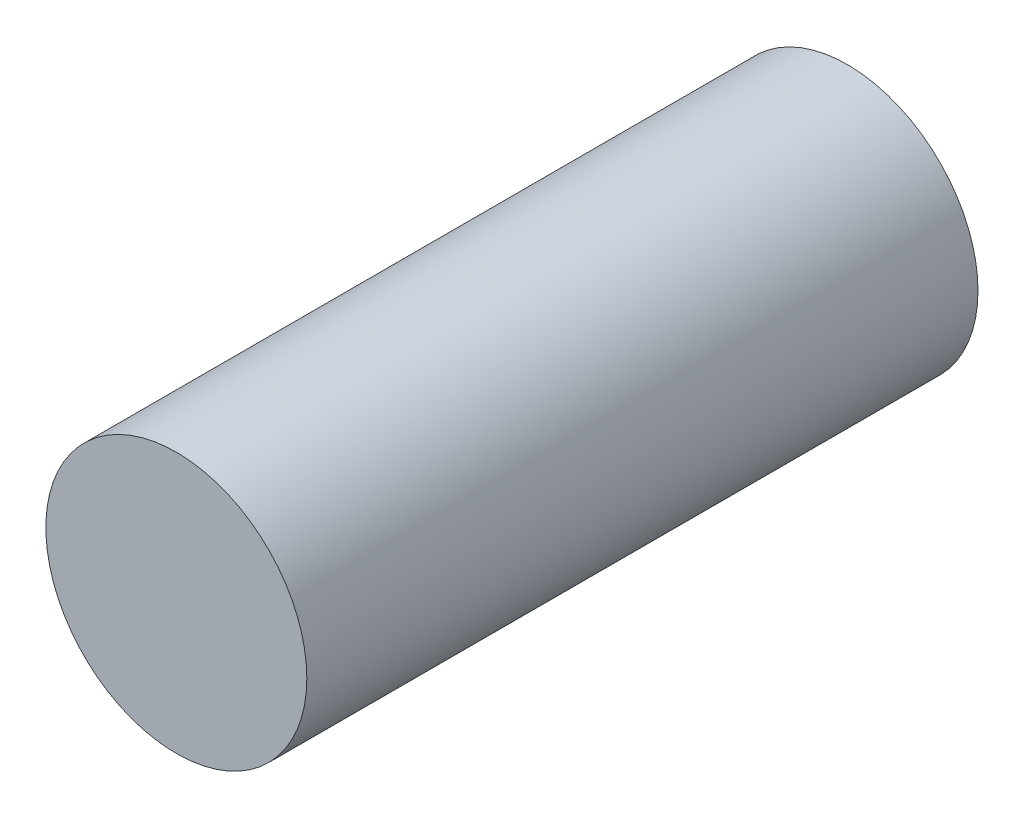
from build123d import *

# Parameters (mm, degrees)
SKETCH1_R           = 4
BOSS_EXTRUDE1_DEPTH = 20.574


with BuildPart() as part:
    # Sketch1 → Boss-Extrude1 (new body)
    with BuildSketch(Plane.XY):
        Circle(SKETCH1_R)
    extrude(amount=BOSS_EXTRUDE1_DEPTH)


solid = part.part
